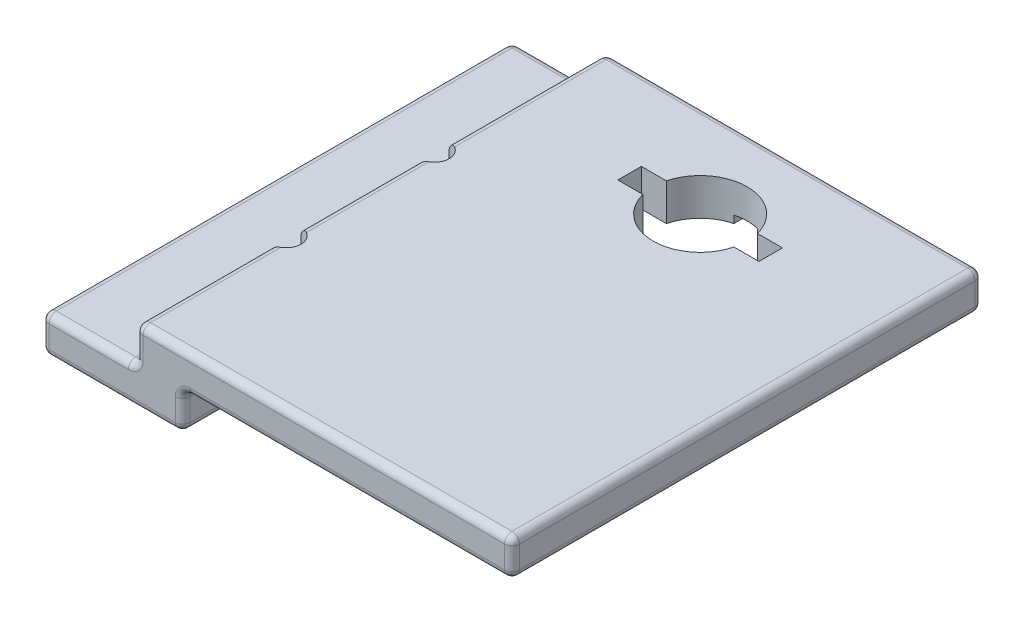
from build123d import *

# Parameters (mm, degrees)
SKETCH1_W           = 63.5
SKETCH1_H           = 10
BOSS_EXTRUDE1_DEPTH = 63.5
SKETCH2_W           = 12.7
SKETCH2_H           = 63.5
CUT_EXTRUDE1_DEPTH  = 5
SKETCH3_W           = 44.45
SKETCH3_H           = 63.5
CUT_EXTRUDE2_DEPTH  = 5
SKETCH4_R           = 6.35
CUT_EXTRUDE3_DEPTH  = 5
SKETCH5_W           = 19.05
SKETCH5_H           = 3.175
CUT_EXTRUDE4_DEPTH  = 5
SKETCH6_R           = 2
CUT_EXTRUDE5_DEPTH  = 6
SKETCH7_R           = 1.65
CUT_EXTRUDE6_DEPTH  = 6
FILLET1_R           = 1
SKETCH8_W           = 3.18
SKETCH8_H           = 19.05
CUT_EXTRUDE7_DEPTH  = 1


with BuildPart() as part:
    # Sketch1 → Boss-Extrude1 (new body)
    with BuildSketch(Plane.XY):
        Rectangle(SKETCH1_W, SKETCH1_H)
    extrude(amount=BOSS_EXTRUDE1_DEPTH)

    # Sketch2 → Cut-Extrude1 (cut)
    with BuildSketch(Plane(origin=(0, 5, 0), x_dir=(1, 0, 0), z_dir=(0, 1, 0))):
        with Locations((-25.4, -31.75)):
            Rectangle(SKETCH2_W, SKETCH2_H)
    extrude(amount=-CUT_EXTRUDE1_DEPTH, mode=Mode.SUBTRACT)

    # Sketch3 → Cut-Extrude2 (cut)
    with BuildSketch(Plane.XZ.offset(5)):
        with Locations((9.525, 31.75)):
            Rectangle(SKETCH3_W, SKETCH3_H)
    extrude(amount=-CUT_EXTRUDE2_DEPTH, mode=Mode.SUBTRACT)

    # Sketch4 → Cut-Extrude3 (cut)
    with BuildSketch(Plane(origin=(0, 5, 0), x_dir=(1, 0, 0), z_dir=(0, 1, 0))):
        with Locations((6.35, -12.7)):
            Circle(SKETCH4_R)
    extrude(amount=-CUT_EXTRUDE3_DEPTH, mode=Mode.SUBTRACT)

    # Sketch5 → Cut-Extrude4 (cut)
    with BuildSketch(Plane.XZ):
        with Locations((6.35, 12.7)):
            Rectangle(SKETCH5_W, SKETCH5_H)
    extrude(amount=-CUT_EXTRUDE4_DEPTH, mode=Mode.SUBTRACT)

    # Sketch6 → Cut-Extrude5 (cut, through all)
    with BuildSketch(Plane(origin=(0, 0, 0), x_dir=(1, 0, 0), z_dir=(0, 1, 0))):
        with Locations((-19.05, -43.18)):
            Circle(SKETCH6_R)
        with Locations((-19.05, -23.18)):
            Circle(SKETCH6_R)
    extrude(amount=CUT_EXTRUDE5_DEPTH, mode=Mode.SUBTRACT)

    # Sketch7 → Cut-Extrude6 (cut, through all)
    with BuildSketch(Plane(origin=(0, 0, 0), x_dir=(1, 0, 0), z_dir=(0, 1, 0))):
        with Locations((-19.05, -23.18)):
            Circle(SKETCH7_R)
        with Locations((-19.05, -43.18)):
            Circle(SKETCH7_R)
    extrude(amount=-CUT_EXTRUDE6_DEPTH, mode=Mode.SUBTRACT)

    # Fillet1
    fillet1_edges = [part.edges().sort_by_distance(p)[0] for p in [
        (-31.75, -2.5, 0),
        (-22.225, -5, 63.5),
        (-31.75, -2.5, 63.5),
        (-19.05, 2.5, 0),
        (-19.05, 2.5, 63.5),
        (-19.05, 5, 54.34),
        (-31.75, 0, 31.75),
        (-25.4, 0, 0),
        (-19.05, 0, 10.59),
        (-25.4, 0, 63.5),
        (31.75, 2.5, 0),
        (31.75, 2.5, 63.5),
        (31.75, 0, 31.75),
        (9.525, 0, 0),
        (-12.7, 0, 31.75),
        (-12.7, -2.5, 0),
        (9.525, 0, 63.5),
        (-12.7, -2.5, 63.5),
        (-12.7, -5, 31.75),
        (-22.225, -5, 0),
        (6.35, 5, 0),
        (-31.75, -5, 31.75),
        (31.75, 5, 31.75),
        (6.35, 5, 63.5),
        (-19.05, 0, 33.18),
        (-19.05, 0, 54.34),
        (-19.05, 5, 33.18),
        (-19.05, 5, 10.59),
    ]]
    fillet(fillet1_edges, radius=FILLET1_R)

    # Sketch8 → Cut-Extrude7 (cut)
    with BuildSketch(Plane(origin=(0, 0, 0), x_dir=(-1, 0, 0), z_dir=(0, -1, 0))):
        with Locations((-6.35, -12.7)):
            Rectangle(SKETCH8_W, SKETCH8_H)
    extrude(amount=-CUT_EXTRUDE7_DEPTH, mode=Mode.SUBTRACT)


solid = part.part
